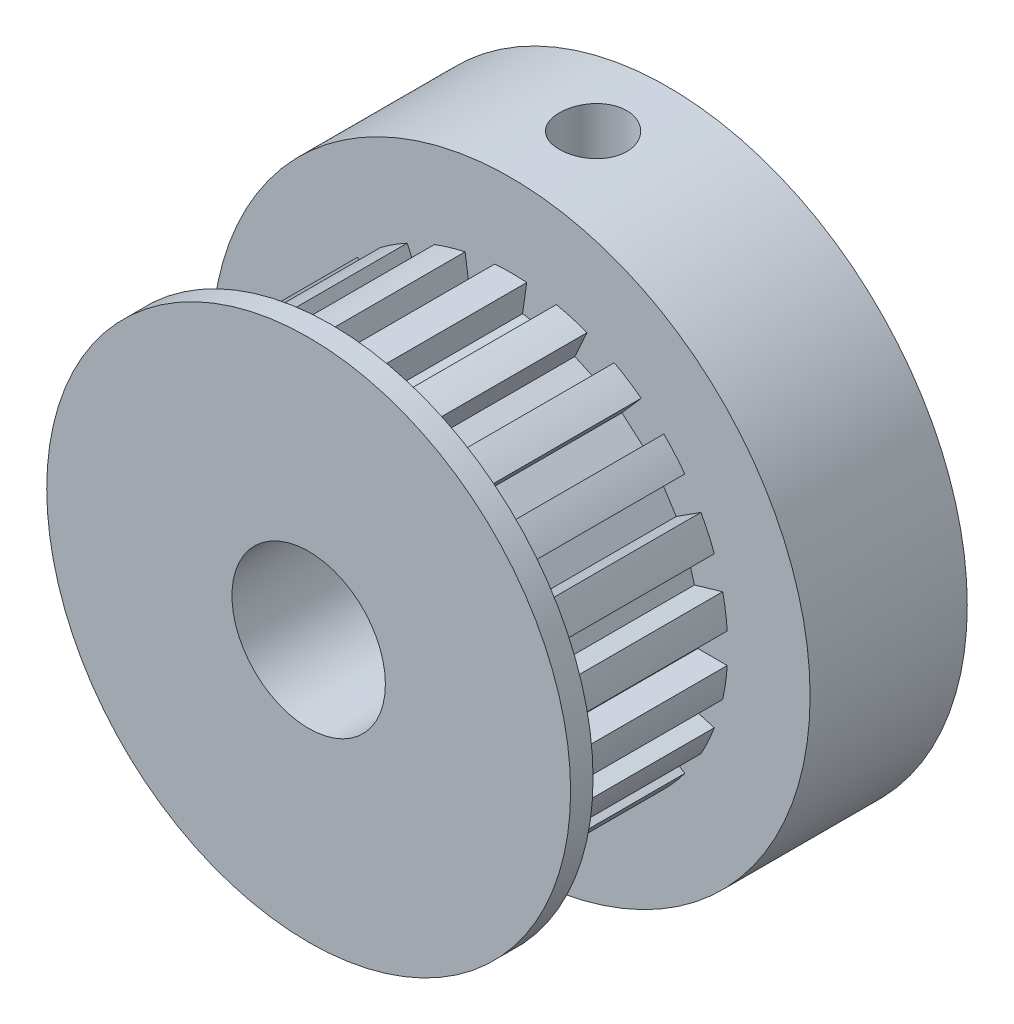
from build123d import *

# Parameters (mm, degrees)
SKETCH1_R               = 8.89
BOSS_EXTRUDE1_DEPTH     = 0.762
SKETCH2_R               = 7.366
BOSS_EXTRUDE2_DEPTH     = 6.096
SKETCH3_R               = 10.16
BOSS_EXTRUDE3_DEPTH     = 5.334
SKETCH4_R               = 2.6035
CUT_EXTRUDE1_DEPTH      = 25.654
SKETCH5_W               = 6.096
SKETCH5_H               = 1.016
CUT_EXTRUDE2_DEPTH      = 1.016
CIRPATTERN1_COUNT       = 22
CUT_EXTRUDE3_DEPTH      = 22.098
CUT_EXTRUDE3_DEPTH_BACK = 22.098
SKETCH6_R               = 1.143


with BuildPart() as part:
    # Sketch1 → Boss-Extrude1 (new body)
    with BuildSketch(Plane.XY):
        Circle(SKETCH1_R)
    extrude(amount=-BOSS_EXTRUDE1_DEPTH)

    # Sketch2 → Boss-Extrude2 (add)
    with BuildSketch(Plane(origin=(0, 0, -0.762), x_dir=(-1, 0, 0), z_dir=(0, 0, -1))):
        Circle(SKETCH2_R)
    extrude(amount=BOSS_EXTRUDE2_DEPTH)

    # Sketch3 → Boss-Extrude3 (add)
    with BuildSketch(Plane(origin=(0, 0, -6.858), x_dir=(-1, 0, 0), z_dir=(0, 0, -1))):
        Circle(SKETCH3_R)
    extrude(amount=BOSS_EXTRUDE3_DEPTH)

    # Sketch4 → Cut-Extrude1 (cut)
    with BuildSketch(Plane.XY):
        Circle(SKETCH4_R)
    extrude(amount=-CUT_EXTRUDE1_DEPTH, mode=Mode.SUBTRACT)

    # Sketch5 → Cut-Extrude2 (cut)
    with BuildSketch(Plane.ZY.offset(7.366)):
        with Locations((-3.81, 0)):
            Rectangle(SKETCH5_W, SKETCH5_H)
    cut_extrude2 = extrude(amount=-CUT_EXTRUDE2_DEPTH, mode=Mode.SUBTRACT)

    # CirPattern1: Cut-Extrude2 ×22 about axis
    cirpattern1_axis = Axis((0, 0, -12.192), (0, 0, 1))
    for i in range(1, CIRPATTERN1_COUNT):
        add(cut_extrude2.rotate(cirpattern1_axis, i * 360 / CIRPATTERN1_COUNT), mode=Mode.SUBTRACT)

    # Sketch6 → Cut-Extrude3 (cut, two sides: drawn at the far end of the back side and taken through both)
    with BuildSketch(Plane(origin=(0, 0, 0), x_dir=(1, 0, 0), z_dir=(0, 1, 0)).offset(-CUT_EXTRUDE3_DEPTH_BACK)):
        with Locations((0, 9.652)):
            Circle(SKETCH6_R)
    extrude(amount=CUT_EXTRUDE3_DEPTH + CUT_EXTRUDE3_DEPTH_BACK, mode=Mode.SUBTRACT)


solid = part.part
